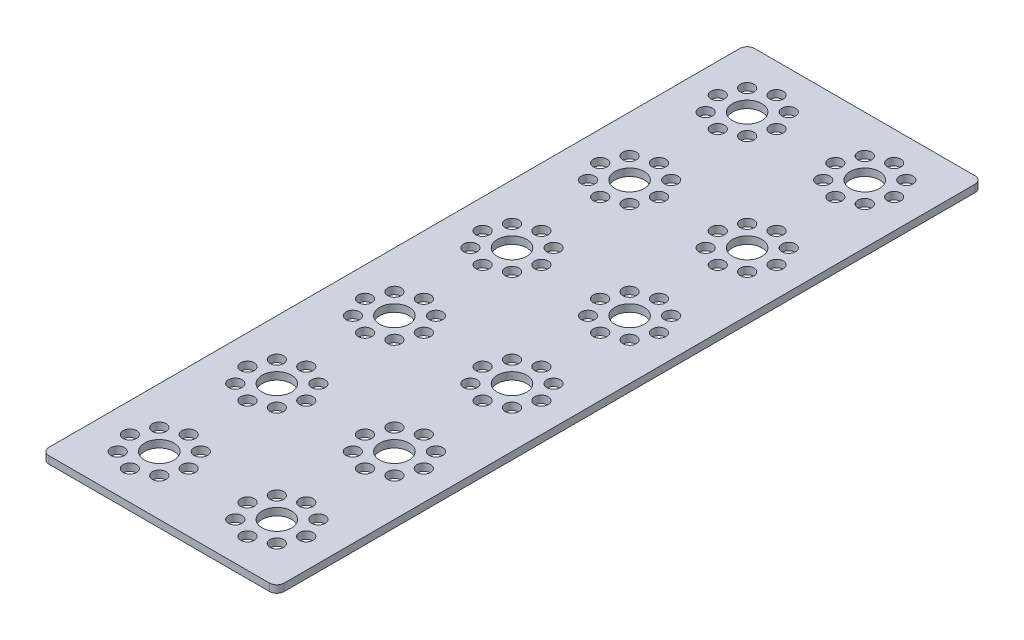
from build123d import *

# Parameters (mm, degrees)
SKETCH1_R           = 1.85
SKETCH1_R_2         = 4
BOSS_EXTRUDE1_DEPTH = 2


with BuildPart() as part:
    # Sketch1 → Boss-Extrude1 (new body)
    with BuildSketch(Plane.XZ):
        with BuildLine():
            Line((48, -174), (48, 14))
            ThreePointArc((48, 14), (47.414213562, 15.414213562), (46, 16))
            Line((46, 16), (-14, 16))
            ThreePointArc((-14, 16), (-15.414213562, 15.414213562), (-16, 14))
            Line((-16, 14), (-16, -174))
            ThreePointArc((-16, -174), (-15.414213562, -175.414213562), (-14, -176))
            Line((-14, -176), (46, -176))
            ThreePointArc((46, -176), (47.414213562, -175.414213562), (48, -174))
        make_face()
        with Locations((37.656854249, -154.343145751)):
            Circle(SKETCH1_R, mode=Mode.SUBTRACT)
        with Locations((26.343145751, -154.343145751)):
            Circle(SKETCH1_R, mode=Mode.SUBTRACT)
        with Locations((26.343145751, -165.656854249)):
            Circle(SKETCH1_R, mode=Mode.SUBTRACT)
        with Locations((37.656854249, -165.656854249)):
            Circle(SKETCH1_R, mode=Mode.SUBTRACT)
        with Locations((24, -160)):
            Circle(SKETCH1_R, mode=Mode.SUBTRACT)
        with Locations((32, -152)):
            Circle(SKETCH1_R, mode=Mode.SUBTRACT)
        with Locations((40, -160)):
            Circle(SKETCH1_R, mode=Mode.SUBTRACT)
        with Locations((32, -168)):
            Circle(SKETCH1_R, mode=Mode.SUBTRACT)
        with Locations((32, -160)):
            Circle(SKETCH1_R_2, mode=Mode.SUBTRACT)
        with Locations((5.656854249, -154.343145751)):
            Circle(SKETCH1_R, mode=Mode.SUBTRACT)
        with Locations((-5.656854249, -154.343145751)):
            Circle(SKETCH1_R, mode=Mode.SUBTRACT)
        with Locations((-5.656854249, -165.656854249)):
            Circle(SKETCH1_R, mode=Mode.SUBTRACT)
        with Locations((5.656854249, -165.656854249)):
            Circle(SKETCH1_R, mode=Mode.SUBTRACT)
        with Locations((-8, -160)):
            Circle(SKETCH1_R, mode=Mode.SUBTRACT)
        with Locations((0, -152)):
            Circle(SKETCH1_R, mode=Mode.SUBTRACT)
        with Locations((8, -160)):
            Circle(SKETCH1_R, mode=Mode.SUBTRACT)
        with Locations((0, -168)):
            Circle(SKETCH1_R, mode=Mode.SUBTRACT)
        with Locations((0, -160)):
            Circle(SKETCH1_R_2, mode=Mode.SUBTRACT)
        with Locations((37.656854249, -122.34314575)):
            Circle(SKETCH1_R, mode=Mode.SUBTRACT)
        with Locations((26.343145751, -122.34314575)):
            Circle(SKETCH1_R, mode=Mode.SUBTRACT)
        with Locations((26.343145751, -133.656854249)):
            Circle(SKETCH1_R, mode=Mode.SUBTRACT)
        with Locations((37.656854249, -133.656854249)):
            Circle(SKETCH1_R, mode=Mode.SUBTRACT)
        with Locations((24, -128)):
            Circle(SKETCH1_R, mode=Mode.SUBTRACT)
        with Locations((32, -120)):
            Circle(SKETCH1_R, mode=Mode.SUBTRACT)
        with Locations((40, -128)):
            Circle(SKETCH1_R, mode=Mode.SUBTRACT)
        with Locations((32, -136)):
            Circle(SKETCH1_R, mode=Mode.SUBTRACT)
        with Locations((32, -128)):
            Circle(SKETCH1_R_2, mode=Mode.SUBTRACT)
        with Locations((5.656854249, -122.34314575)):
            Circle(SKETCH1_R, mode=Mode.SUBTRACT)
        with Locations((-5.656854249, -122.34314575)):
            Circle(SKETCH1_R, mode=Mode.SUBTRACT)
        with Locations((-5.656854249, -133.656854249)):
            Circle(SKETCH1_R, mode=Mode.SUBTRACT)
        with Locations((5.656854249, -133.656854249)):
            Circle(SKETCH1_R, mode=Mode.SUBTRACT)
        with Locations((-8, -128)):
            Circle(SKETCH1_R, mode=Mode.SUBTRACT)
        with Locations((0, -120)):
            Circle(SKETCH1_R, mode=Mode.SUBTRACT)
        with Locations((8, -128)):
            Circle(SKETCH1_R, mode=Mode.SUBTRACT)
        with Locations((0, -136)):
            Circle(SKETCH1_R, mode=Mode.SUBTRACT)
        with Locations((0, -128)):
            Circle(SKETCH1_R_2, mode=Mode.SUBTRACT)
        with Locations((37.656854249, -90.343145751)):
            Circle(SKETCH1_R, mode=Mode.SUBTRACT)
        with Locations((26.343145751, -90.343145751)):
            Circle(SKETCH1_R, mode=Mode.SUBTRACT)
        with Locations((26.343145751, -101.65685425)):
            Circle(SKETCH1_R, mode=Mode.SUBTRACT)
        with Locations((37.656854249, -101.65685425)):
            Circle(SKETCH1_R, mode=Mode.SUBTRACT)
        with Locations((24, -96)):
            Circle(SKETCH1_R, mode=Mode.SUBTRACT)
        with Locations((32, -88)):
            Circle(SKETCH1_R, mode=Mode.SUBTRACT)
        with Locations((40, -96)):
            Circle(SKETCH1_R, mode=Mode.SUBTRACT)
        with Locations((32, -104)):
            Circle(SKETCH1_R, mode=Mode.SUBTRACT)
        with Locations((32, -96)):
            Circle(SKETCH1_R_2, mode=Mode.SUBTRACT)
        with Locations((5.656854249, -90.343145751)):
            Circle(SKETCH1_R, mode=Mode.SUBTRACT)
        with Locations((-5.656854249, -90.343145751)):
            Circle(SKETCH1_R, mode=Mode.SUBTRACT)
        with Locations((-5.656854249, -101.65685425)):
            Circle(SKETCH1_R, mode=Mode.SUBTRACT)
        with Locations((5.656854249, -101.65685425)):
            Circle(SKETCH1_R, mode=Mode.SUBTRACT)
        with Locations((-8, -96)):
            Circle(SKETCH1_R, mode=Mode.SUBTRACT)
        with Locations((0, -88)):
            Circle(SKETCH1_R, mode=Mode.SUBTRACT)
        with Locations((8, -96)):
            Circle(SKETCH1_R, mode=Mode.SUBTRACT)
        with Locations((0, -104)):
            Circle(SKETCH1_R, mode=Mode.SUBTRACT)
        with Locations((0, -96)):
            Circle(SKETCH1_R_2, mode=Mode.SUBTRACT)
        with Locations((37.656854249, -58.343145751)):
            Circle(SKETCH1_R, mode=Mode.SUBTRACT)
        with Locations((26.343145751, -58.343145751)):
            Circle(SKETCH1_R, mode=Mode.SUBTRACT)
        with Locations((26.343145751, -69.656854249)):
            Circle(SKETCH1_R, mode=Mode.SUBTRACT)
        with Locations((37.656854249, -69.656854249)):
            Circle(SKETCH1_R, mode=Mode.SUBTRACT)
        with Locations((24, -64)):
            Circle(SKETCH1_R, mode=Mode.SUBTRACT)
        with Locations((32, -56)):
            Circle(SKETCH1_R, mode=Mode.SUBTRACT)
        with Locations((40, -64)):
            Circle(SKETCH1_R, mode=Mode.SUBTRACT)
        with Locations((32, -72)):
            Circle(SKETCH1_R, mode=Mode.SUBTRACT)
        with Locations((32, -64)):
            Circle(SKETCH1_R_2, mode=Mode.SUBTRACT)
        with Locations((5.656854249, -58.343145751)):
            Circle(SKETCH1_R, mode=Mode.SUBTRACT)
        with Locations((-5.656854249, -58.343145751)):
            Circle(SKETCH1_R, mode=Mode.SUBTRACT)
        with Locations((-5.656854249, -69.656854249)):
            Circle(SKETCH1_R, mode=Mode.SUBTRACT)
        with Locations((5.656854249, -69.656854249)):
            Circle(SKETCH1_R, mode=Mode.SUBTRACT)
        with Locations((-8, -64)):
            Circle(SKETCH1_R, mode=Mode.SUBTRACT)
        with Locations((0, -56)):
            Circle(SKETCH1_R, mode=Mode.SUBTRACT)
        with Locations((8, -64)):
            Circle(SKETCH1_R, mode=Mode.SUBTRACT)
        with Locations((0, -72)):
            Circle(SKETCH1_R, mode=Mode.SUBTRACT)
        with Locations((0, -64)):
            Circle(SKETCH1_R_2, mode=Mode.SUBTRACT)
        Circle(SKETCH1_R_2, mode=Mode.SUBTRACT)
        with Locations((37.656854249, -26.343145751)):
            Circle(SKETCH1_R, mode=Mode.SUBTRACT)
        with Locations((26.343145751, -26.343145751)):
            Circle(SKETCH1_R, mode=Mode.SUBTRACT)
        with Locations((26.343145751, -37.656854249)):
            Circle(SKETCH1_R, mode=Mode.SUBTRACT)
        with Locations((37.656854249, -37.656854249)):
            Circle(SKETCH1_R, mode=Mode.SUBTRACT)
        with Locations((24, -32)):
            Circle(SKETCH1_R, mode=Mode.SUBTRACT)
        with Locations((32, -24)):
            Circle(SKETCH1_R, mode=Mode.SUBTRACT)
        with Locations((40, -32)):
            Circle(SKETCH1_R, mode=Mode.SUBTRACT)
        with Locations((32, -40)):
            Circle(SKETCH1_R, mode=Mode.SUBTRACT)
        with Locations((32, -32)):
            Circle(SKETCH1_R_2, mode=Mode.SUBTRACT)
        with Locations((5.656854249, -26.343145751)):
            Circle(SKETCH1_R, mode=Mode.SUBTRACT)
        with Locations((-5.656854249, -26.343145751)):
            Circle(SKETCH1_R, mode=Mode.SUBTRACT)
        with Locations((-5.656854249, -37.656854249)):
            Circle(SKETCH1_R, mode=Mode.SUBTRACT)
        with Locations((5.656854249, -37.656854249)):
            Circle(SKETCH1_R, mode=Mode.SUBTRACT)
        with Locations((-8, -32)):
            Circle(SKETCH1_R, mode=Mode.SUBTRACT)
        with Locations((0, -24)):
            Circle(SKETCH1_R, mode=Mode.SUBTRACT)
        with Locations((8, -32)):
            Circle(SKETCH1_R, mode=Mode.SUBTRACT)
        with Locations((0, -40)):
            Circle(SKETCH1_R, mode=Mode.SUBTRACT)
        with Locations((0, -32)):
            Circle(SKETCH1_R_2, mode=Mode.SUBTRACT)
        with Locations((37.656854249, 5.656854249)):
            Circle(SKETCH1_R, mode=Mode.SUBTRACT)
        with Locations((26.343145751, 5.656854249)):
            Circle(SKETCH1_R, mode=Mode.SUBTRACT)
        with Locations((26.343145751, -5.656854249)):
            Circle(SKETCH1_R, mode=Mode.SUBTRACT)
        with Locations((37.656854249, -5.656854249)):
            Circle(SKETCH1_R, mode=Mode.SUBTRACT)
        with Locations((24, 0)):
            Circle(SKETCH1_R, mode=Mode.SUBTRACT)
        with Locations((32, 8)):
            Circle(SKETCH1_R, mode=Mode.SUBTRACT)
        with Locations((40, 0)):
            Circle(SKETCH1_R, mode=Mode.SUBTRACT)
        with Locations((32, -8)):
            Circle(SKETCH1_R, mode=Mode.SUBTRACT)
        with Locations((32, 0)):
            Circle(SKETCH1_R_2, mode=Mode.SUBTRACT)
        with Locations((5.656854249, 5.656854249)):
            Circle(SKETCH1_R, mode=Mode.SUBTRACT)
        with Locations((-5.656854249, 5.656854249)):
            Circle(SKETCH1_R, mode=Mode.SUBTRACT)
        with Locations((-5.656854249, -5.656854249)):
            Circle(SKETCH1_R, mode=Mode.SUBTRACT)
        with Locations((5.656854249, -5.656854249)):
            Circle(SKETCH1_R, mode=Mode.SUBTRACT)
        with Locations((-8, 0)):
            Circle(SKETCH1_R, mode=Mode.SUBTRACT)
        with Locations((0, 8)):
            Circle(SKETCH1_R, mode=Mode.SUBTRACT)
        with Locations((8, 0)):
            Circle(SKETCH1_R, mode=Mode.SUBTRACT)
        with Locations((0, -8)):
            Circle(SKETCH1_R, mode=Mode.SUBTRACT)
    extrude(amount=-BOSS_EXTRUDE1_DEPTH)


solid = part.part
